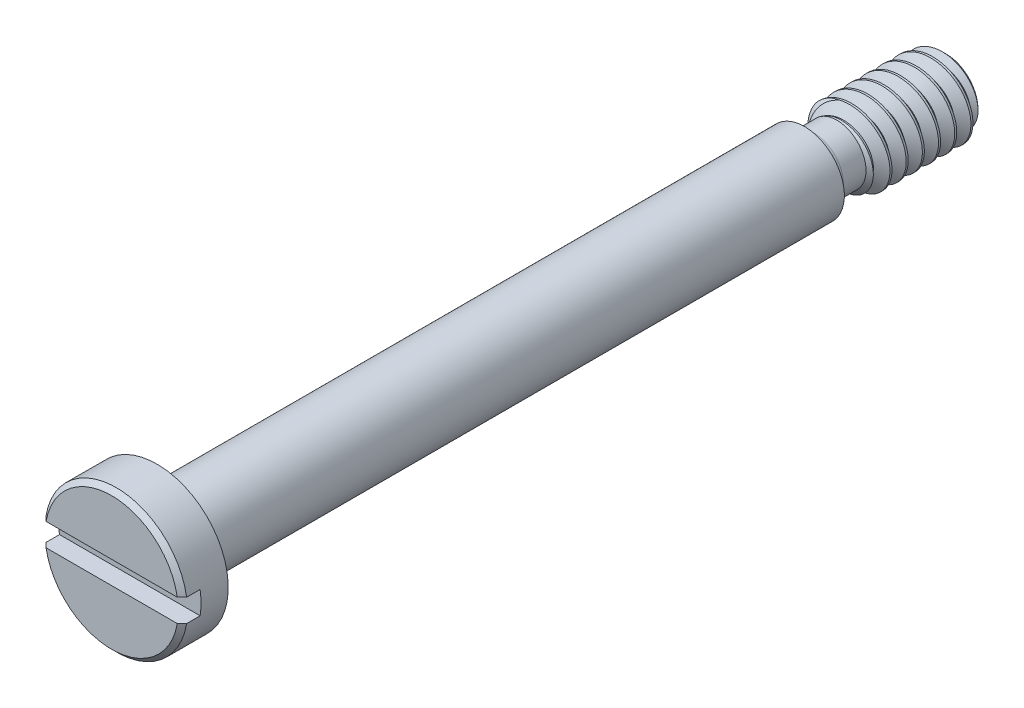
from build123d import *

# Parameters (mm, degrees)
SKETCH8_W              = 2.794
SKETCH8_H              = 0.44704
CUT_EXTRUDE2_DEPTH     = 0.3556
CHAMFER1_SIZE          = 0.090805
CHAMFER2_SIZE          = 0.13716
CUT_SWEEP1_PITCH       = 0.3175
CUT_SWEEP1_HEIGHT      = 2.778125
CUT_SWEEP1_RADIUS      = 0.762
CUT_SWEEP1_START_ANGLE = 90


with BuildPart() as part:
    # Sketch12 → Revolve1 (revolve)
    with BuildSketch(Plane(origin=(0, 0, 0), x_dir=(0, 0, -1), z_dir=(1, 0, 0)), mode=Mode.PRIVATE) as revolve1_sk:
        Polygon((-7.2945625, 1.397), (-7.2945625, 0.78105), (5.4054375, 0.78105), (5.4054375, 0.762), (8.1835625, 0.762), (8.1835625, 0), (-8.1835625, 0), (-8.1835625, 1.397), align=None)
    revolve(revolve1_sk.sketch.rotate(Axis((0, 0, -8.1835625), (0, 0, 1)), 90), axis=Axis((0, 0, -8.1835625), (0, 0, 1)))

    # Sketch5 → Cut-Revolve1 (revolve, cut)
    with BuildSketch(Plane(origin=(0, 0, 0), x_dir=(0, 0, -1), z_dir=(1, 0, 0))):
        with BuildLine():
            Line((5.4054375, 0.78105), (6.2499875, 0.78105))
            Line((6.2499875, 0.78105), (6.0404375, 0.5715))
            Line((6.0404375, 0.5715), (5.5959375, 0.5715))
            ThreePointArc((5.5959375, 0.5715), (5.461233658, 0.627296158), (5.4054375, 0.762))
            Line((5.4054375, 0.762), (5.4054375, 0.78105))
        make_face()
    revolve(axis=Axis((0, 0, -8.1835625), (0, 0, 1)), mode=Mode.SUBTRACT)

    # Sketch8 → Cut-Extrude2 (cut)
    with BuildSketch(Plane.XY.offset(8.1835625)):
        Rectangle(SKETCH8_W, SKETCH8_H)
    extrude(amount=-CUT_EXTRUDE2_DEPTH, mode=Mode.SUBTRACT)

    # Chamfer1
    chamfer1_edges = [part.edges().sort_by_distance(p)[0] for p in [
        (0, 1.397, 8.1835625),
        (0, -1.397, 8.1835625),
    ]]
    chamfer(chamfer1_edges, length=CHAMFER1_SIZE)

    # Chamfer2
    chamfer2_edges = [part.edges().sort_by_distance(p)[0] for p in [
        (0.762, 0, -8.1835625),
    ]]
    chamfer(chamfer2_edges, length=CHAMFER2_SIZE)


with BuildPart() as body_2:
    # Split2: the piece on the far side of the plane
    add(part.part)
    split(bisect_by=Plane.XY.offset(-6.0404375), keep=Keep.BOTTOM)

    # Cut-Sweep1: sweep along a helix
    with BuildLine() as cut_sweep1_path:
        add(Helix(CUT_SWEEP1_PITCH, CUT_SWEEP1_HEIGHT, CUT_SWEEP1_RADIUS, center=(0, 0, -8.1835625), direction=(0, 0, 1), mode=Mode.PRIVATE).rotate(Axis((0, 0, -8.1835625), (0, 0, 1)), CUT_SWEEP1_START_ANGLE))
    # Sketch10 → Cut-Sweep1 (sweep, cut)
    with BuildSketch(Plane(origin=(0, 0, 0), x_dir=(0, 0, -1), z_dir=(1, 0, 0))):
        Polygon((8.302625, 0.555777701), (8.3423125, 0.555777701), (8.471296875, 0.779185192), (8.173640625, 0.779185192), align=None)
    sweep(path=cut_sweep1_path.line, is_frenet=True, mode=Mode.SUBTRACT)


with BuildPart() as part_1:
    add(part.part)

    # Split2
    split(bisect_by=Plane.XY.offset(-6.0404375), keep=Keep.TOP)


with BuildPart() as body_2_1:
    add(body_2.part)

    # Combine1: union part
    add(part_1.part)


solid = body_2_1.part
